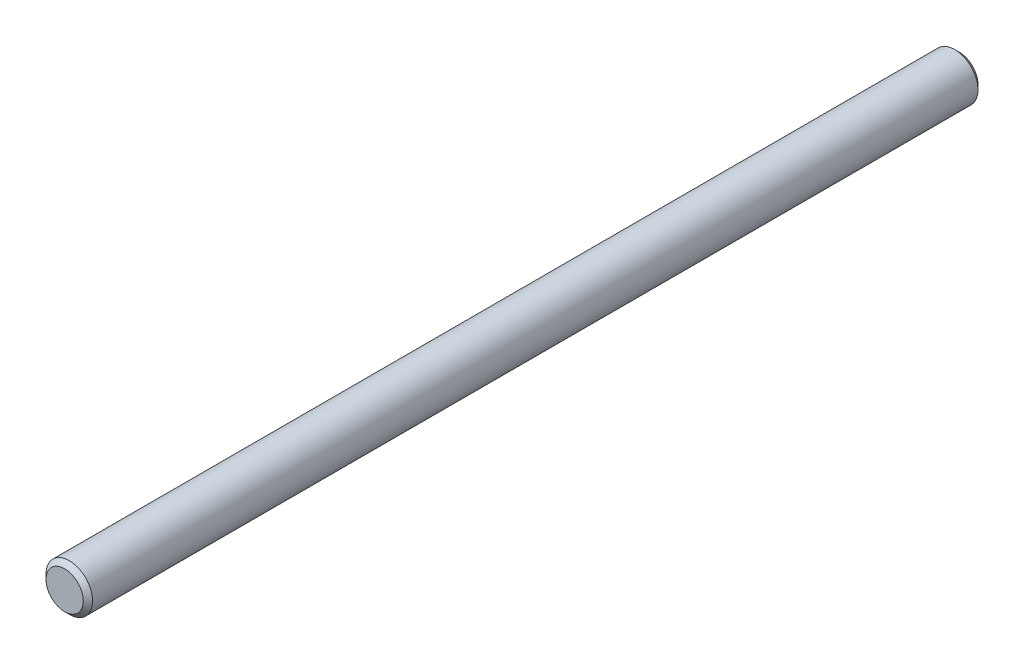
from build123d import *

# Parameters (mm, degrees)
SKETCH1_R      = 7.9375
EXTRUDE1_DEPTH = 152.4
CHAMFER1_SIZE  = 1.5875


with BuildPart() as part:
    # Sketch1 → Extrude1 (new body, symmetric)
    with BuildSketch(Plane.XY):
        Circle(SKETCH1_R)
    extrude(amount=EXTRUDE1_DEPTH, both=True)

    # Chamfer1
    chamfer1_edges = [part.edges().sort_by_distance(p)[0] for p in [
        (-7.9375, 0, -152.4),
        (-7.9375, 0, 152.4),
    ]]
    chamfer(chamfer1_edges, length=CHAMFER1_SIZE)


solid = part.part
